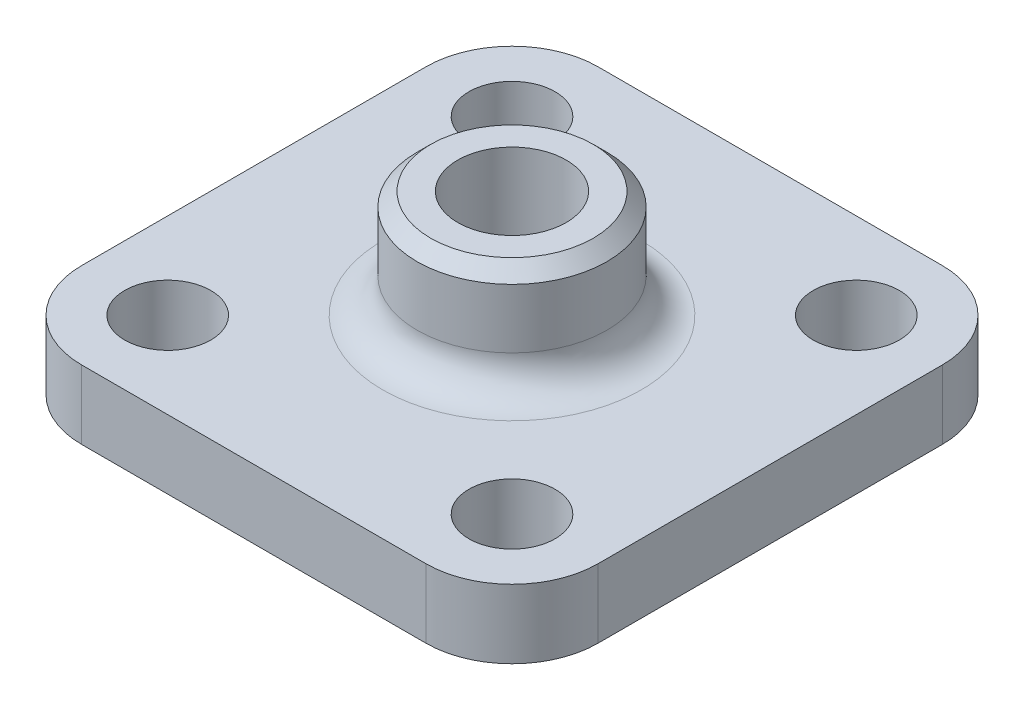
from build123d import *

# Parameters (mm, degrees)
SKETCH1_W                   = 38.1
SKETCH1_H                   = 38.1
SKETCH1_R                   = 4
BOSS_EXTRUDE1_DEPTH         = 5.08
F_1_4_0_25_DIAMETER_HOLE1_D = 6.35
SKETCH5_R                   = 7
SKETCH5_R_2                 = 4
BOSS_EXTRUDE2_DEPTH         = 7.92
FILLET1_R                   = 2.54
CHAMFER1_SIZE               = 1
FILLET2_R                   = 6.35


with BuildPart() as part:
    # Sketch1 → Boss-Extrude1 (new body)
    with BuildSketch(Plane(origin=(0, 0, 0), x_dir=(1, 0, 0), z_dir=(0, 1, 0))):
        Rectangle(SKETCH1_W, SKETCH1_H)
        Circle(SKETCH1_R, mode=Mode.SUBTRACT)
    extrude(amount=BOSS_EXTRUDE1_DEPTH)

    # 1/4 (0.25) Diameter Hole1 (through all)
    with Locations(Plane(origin=(0, 5.08, 0), x_dir=(1, 0, 0), z_dir=(0, 1, 0))):
        with Locations((-12.7, 12.7), (12.7, 12.7), (12.7, -12.7), (-12.7, -12.7)):
            Hole(F_1_4_0_25_DIAMETER_HOLE1_D / 2)

    # Sketch5 → Boss-Extrude2 (add)
    with BuildSketch(Plane(origin=(0, 5.08, 0), x_dir=(1, 0, 0), z_dir=(0, 1, 0))):
        Circle(SKETCH5_R)
        Circle(SKETCH5_R_2, mode=Mode.SUBTRACT)
    extrude(amount=BOSS_EXTRUDE2_DEPTH)

    # Fillet1
    fillet1_edges = [part.edges().sort_by_distance(p)[0] for p in [
        (-7, 5.08, 0),
    ]]
    fillet(fillet1_edges, radius=FILLET1_R)

    # Chamfer1
    chamfer1_edges = [part.edges().sort_by_distance(p)[0] for p in [
        (-7, 13, 0),
    ]]
    chamfer(chamfer1_edges, length=CHAMFER1_SIZE)

    # Fillet2
    fillet2_edges = [part.edges().sort_by_distance(p)[0] for p in [
        (19.05, 2.54, 19.05),
        (-19.05, 2.54, 19.05),
        (-19.05, 2.54, -19.05),
        (19.05, 2.54, -19.05),
    ]]
    fillet(fillet2_edges, radius=FILLET2_R)


solid = part.part
